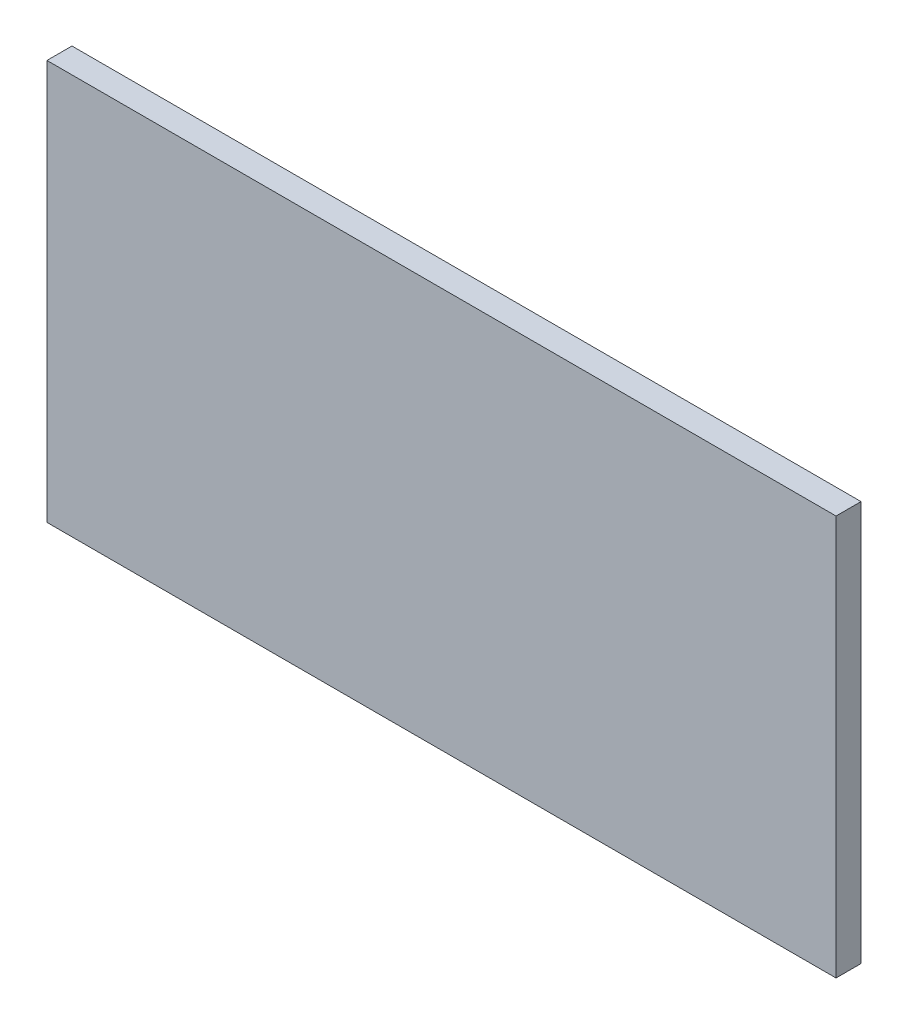
from build123d import *

# Parameters (mm, degrees)
SKETCH1_W           = 568
SKETCH1_H           = 288
BOSS_EXTRUDE1_DEPTH = 18


with BuildPart() as part:
    # Sketch1 → Boss-Extrude1 (new body)
    with BuildSketch(Plane.XY):
        Rectangle(SKETCH1_W, SKETCH1_H)
    extrude(amount=BOSS_EXTRUDE1_DEPTH)


solid = part.part
